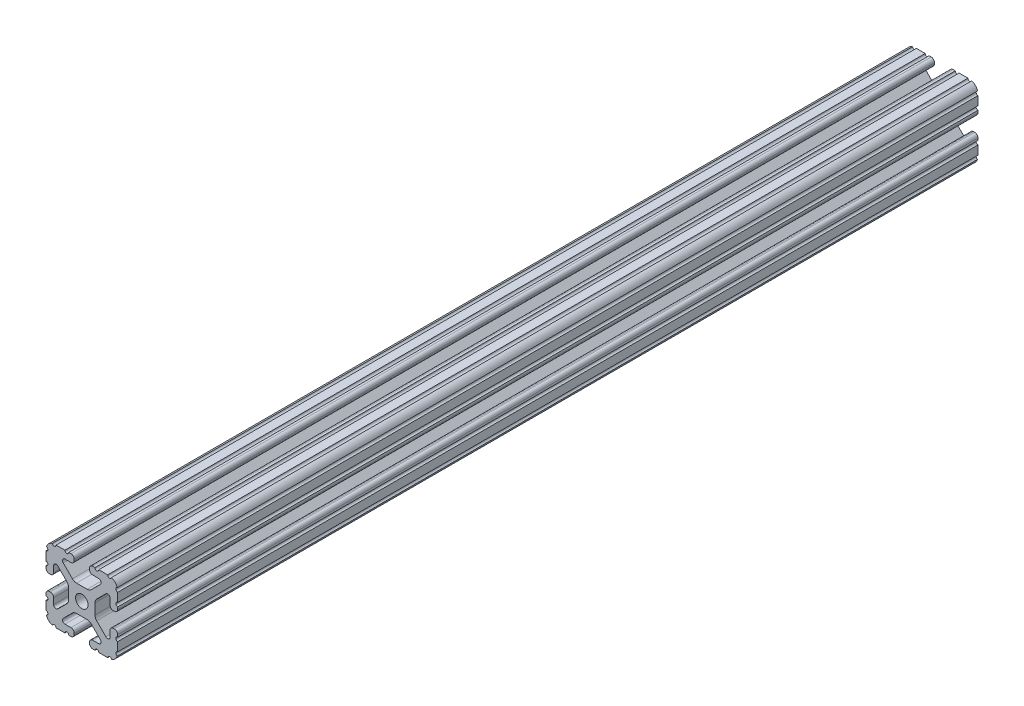
from build123d import *

# Parameters (mm, degrees)
BOSS_EXTRUDE1_DEPTH     = 228.6
SKETCH5_R               = 1.016
CUT_EXTRUDE1_DEPTH      = 229.6
CUT_EXTRUDE1_DEPTH_BACK = 229.6


with BuildPart() as part:
    # Sketch4 → Boss-Extrude1 (new body, symmetric)
    with BuildSketch(Plane.XY):
        with BuildLine():
            Line((5.7912, -19.05), (14.3002, -19.05))
            ThreePointArc((14.3002, -19.05), (17.658815789, -17.658815789), (19.05, -14.3002))
            Line((19.05, -14.3002), (19.05, -5.7912))
            ThreePointArc((19.05, -5.7912), (18.544114832, -4.569885168), (17.3228, -4.064))
            Line((17.3228, -4.064), (16.7132, -4.064))
            ThreePointArc((16.7132, -4.064), (15.491885168, -4.569885168), (14.986, -5.7912))
            Line((14.986, -5.7912), (14.986, -8.996305235))
            ThreePointArc((14.986, -8.996305235), (14.189232738, -10.188751711), (12.782646215, -9.908964256))
            Line((12.782646215, -9.908964256), (7.888897763, -5.015215804))
            ThreePointArc((7.888897763, -5.015215804), (7.219915375, -4.014012907), (6.985, -2.833013566))
            Line((6.985, -2.833013566), (6.985, 0))
            Line((6.985, 0), (3.3274, 0))
            ThreePointArc((3.3274, 0), (2.352827104, -2.352827104), (0, -3.3274))
            Line((0, -3.3274), (0, -6.985))
            Line((0, -6.985), (2.833013566, -6.985))
            ThreePointArc((2.833013566, -6.985), (4.014012907, -7.219915375), (5.015215804, -7.888897763))
            Line((5.015215804, -7.888897763), (9.908964256, -12.782646215))
            ThreePointArc((9.908964256, -12.782646215), (10.188751711, -14.189232738), (8.996305235, -14.986))
            Line((8.996305235, -14.986), (5.7912, -14.986))
            ThreePointArc((5.7912, -14.986), (4.569885168, -15.491885168), (4.064, -16.7132))
            Line((4.064, -16.7132), (4.064, -17.3228))
            ThreePointArc((4.064, -17.3228), (4.569885168, -18.544114832), (5.7912, -19.05))
        make_face()
    extrude(amount=BOSS_EXTRUDE1_DEPTH, both=True)

    # Sketch5 → Cut-Extrude1 (cut, two sides)
    with BuildSketch(Plane.XY) as cut_extrude1_sk:
        with Locations((14.739477062, -19.05)):
            Circle(SKETCH5_R)
        with Locations((7.980305235, -19.05)):
            Circle(SKETCH5_R)
        with Locations((19.05, -14.739477062)):
            Circle(SKETCH5_R)
        with Locations((19.05, -7.980305235)):
            Circle(SKETCH5_R)
    extrude(amount=CUT_EXTRUDE1_DEPTH, mode=Mode.SUBTRACT)
    extrude(cut_extrude1_sk.sketch, amount=-CUT_EXTRUDE1_DEPTH_BACK, mode=Mode.SUBTRACT)

    # Mirror1: part across plane


with BuildPart() as part_1:
    add(part.part)
    add(part.part.mirror(Plane(origin=(0, 0, 0), x_dir=(0, 0, 1), z_dir=(1, 0, 0))))

    # Mirror2: part across plane


with BuildPart() as part_2:
    add(part_1.part)
    add(part_1.part.mirror(Plane.ZX))


solid = part_2.part
